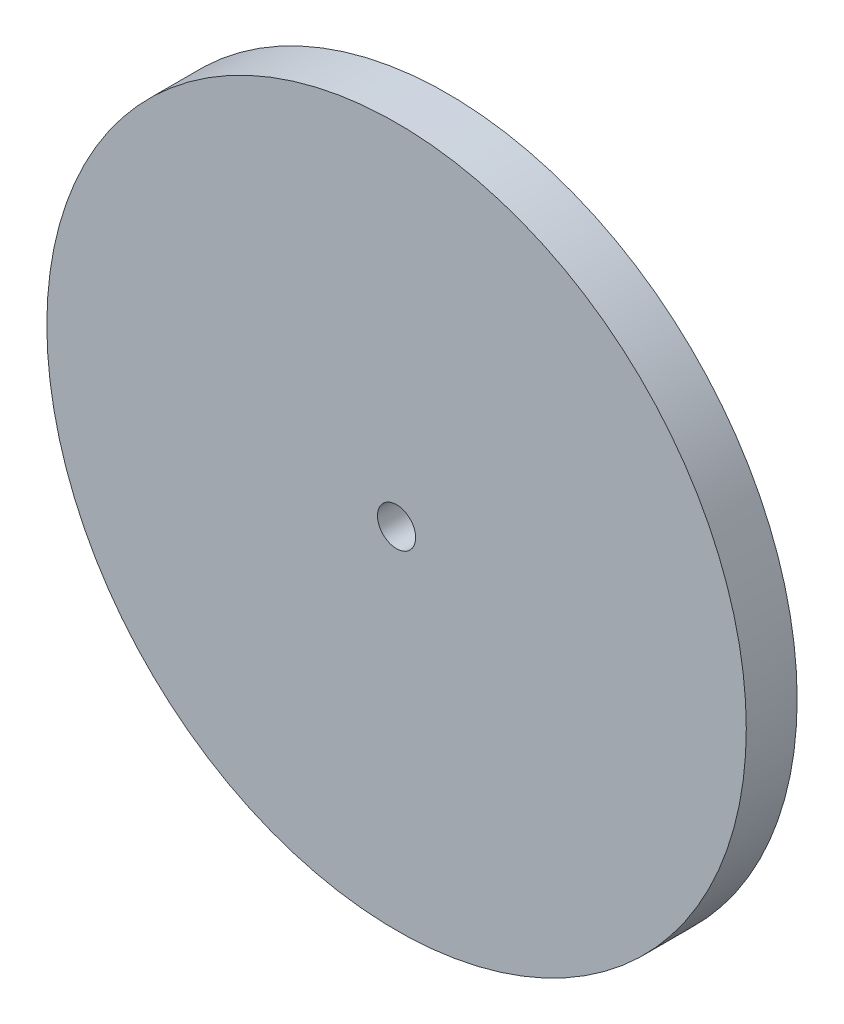
from build123d import *

# Parameters (mm, degrees)
SKETCH1_R           = 17.4625
SKETCH1_R_2         = 0.9525
BOSS_EXTRUDE1_DEPTH = 2.54


with BuildPart() as part:
    # Sketch1 → Boss-Extrude1 (new body)
    with BuildSketch(Plane.XY):
        Circle(SKETCH1_R)
        Circle(SKETCH1_R_2, mode=Mode.SUBTRACT)
    extrude(amount=BOSS_EXTRUDE1_DEPTH)


solid = part.part
